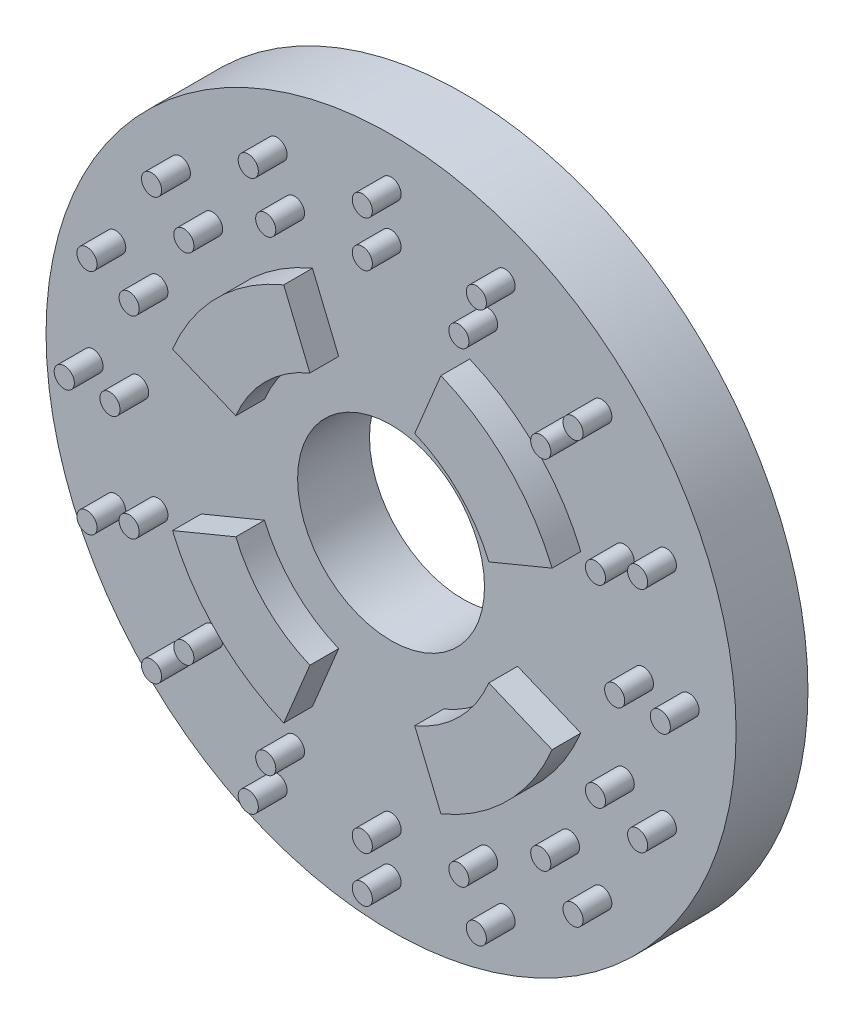
from build123d import *

# Parameters (mm, degrees)
SKETCH1_R          = 24
EXTRUDE1_DEPTH     = 5
SKETCH5_R          = 6.5
CUT_EXTRUDE3_DEPTH = 10
SKETCH4_R          = 0.7
EXTRUDE2_DEPTH     = 2


with BuildPart() as part:
    # Sketch1 → Extrude1 (new body)
    with BuildSketch(Plane.XY):
        Circle(SKETCH1_R)
    extrude(amount=EXTRUDE1_DEPTH)

    # Sketch5 → Cut-Extrude3 (cut)
    with BuildSketch(Plane(origin=(0, 0, 0), x_dir=(-1, 0, 0), z_dir=(0, 0, -1))):
        Circle(SKETCH5_R)
    extrude(amount=-CUT_EXTRUDE3_DEPTH, mode=Mode.SUBTRACT)

    # Sketch4 → Extrude2 (add)
    with BuildSketch(Plane.XY.offset(5)):
        with Locations((0, 20.73)):
            Circle(SKETCH4_R)
        with Locations((0, -20.73)):
            Circle(SKETCH4_R)
        with Locations((20.73, 0)):
            Circle(SKETCH4_R)
        with Locations((-20.73, 0)):
            Circle(SKETCH4_R)
        with Locations((-14.658, 14.658)):
            Circle(SKETCH4_R)
        with Locations((14.658, 14.658)):
            Circle(SKETCH4_R)
        with Locations((14.658, -14.658)):
            Circle(SKETCH4_R)
        with Locations((-14.658, -14.658)):
            Circle(SKETCH4_R)
        with Locations((19.152, 7.933)):
            Circle(SKETCH4_R)
        with Locations((7.933, 19.152)):
            Circle(SKETCH4_R)
        with Locations((19.152, -7.933)):
            Circle(SKETCH4_R)
        with Locations((7.933, -19.152)):
            Circle(SKETCH4_R)
        with Locations((-7.933, 19.152)):
            Circle(SKETCH4_R)
        with Locations((-19.152, 7.933)):
            Circle(SKETCH4_R)
        with Locations((-19.152, -7.933)):
            Circle(SKETCH4_R)
        with Locations((-7.933, -19.152)):
            Circle(SKETCH4_R)
        with Locations((0, 17.555)):
            Circle(SKETCH4_R)
        with Locations((17.555, 0)):
            Circle(SKETCH4_R)
        with Locations((0, -17.555)):
            Circle(SKETCH4_R)
        with Locations((-17.555, 0)):
            Circle(SKETCH4_R)
        with Locations((-12.413, 12.413)):
            Circle(SKETCH4_R)
        with Locations((12.413, 12.413)):
            Circle(SKETCH4_R)
        with Locations((12.413, -12.413)):
            Circle(SKETCH4_R)
        with Locations((-12.413, -12.413)):
            Circle(SKETCH4_R)
        with Locations((-16.218, 6.718)):
            Circle(SKETCH4_R)
        with Locations((16.218, 6.718)):
            Circle(SKETCH4_R)
        with Locations((16.218, -6.718)):
            Circle(SKETCH4_R)
        with Locations((-16.218, -6.718)):
            Circle(SKETCH4_R)
        with Locations((6.718, 16.218)):
            Circle(SKETCH4_R)
        with Locations((6.718, -16.218)):
            Circle(SKETCH4_R)
        with Locations((-6.718, -16.218)):
            Circle(SKETCH4_R)
        with Locations((-6.718, 16.218)):
            Circle(SKETCH4_R)
        with BuildLine():
            Line((3.645052576, -8.799955495), (5.467578865, -13.199933243))
            ThreePointArc((5.467578865, -13.199933243), (10.102788136, -10.102788136), (13.199933243, -5.467578865))
            Line((13.199933243, -5.467578865), (8.799955495, -3.645052576))
            ThreePointArc((8.799955495, -3.645052576), (6.735192091, -6.735192091), (3.645052576, -8.799955495))
        make_face()
        with BuildLine():
            Line((8.799955495, 3.645052576), (13.199933243, 5.467578865))
            ThreePointArc((13.199933243, 5.467578865), (10.102788136, 10.102788136), (5.467578865, 13.199933243))
            Line((5.467578865, 13.199933243), (3.645052576, 8.799955495))
            ThreePointArc((3.645052576, 8.799955495), (6.735192091, 6.735192091), (8.799955495, 3.645052576))
        make_face()
        with BuildLine():
            Line((-3.645052576, 8.799955495), (-5.467578865, 13.199933243))
            ThreePointArc((-5.467578865, 13.199933243), (-10.102788136, 10.102788136), (-13.199933243, 5.467578865))
            Line((-13.199933243, 5.467578865), (-8.799955495, 3.645052576))
            ThreePointArc((-8.799955495, 3.645052576), (-6.735192091, 6.735192091), (-3.645052576, 8.799955495))
        make_face()
        with BuildLine():
            Line((-8.799955495, -3.645052576), (-13.199933243, -5.467578865))
            ThreePointArc((-13.199933243, -5.467578865), (-10.102788136, -10.102788136), (-5.467578865, -13.199933243))
            Line((-5.467578865, -13.199933243), (-3.645052576, -8.799955495))
            ThreePointArc((-3.645052576, -8.799955495), (-6.735192091, -6.735192091), (-8.799955495, -3.645052576))
        make_face()
    extrude(amount=EXTRUDE2_DEPTH)


solid = part.part
